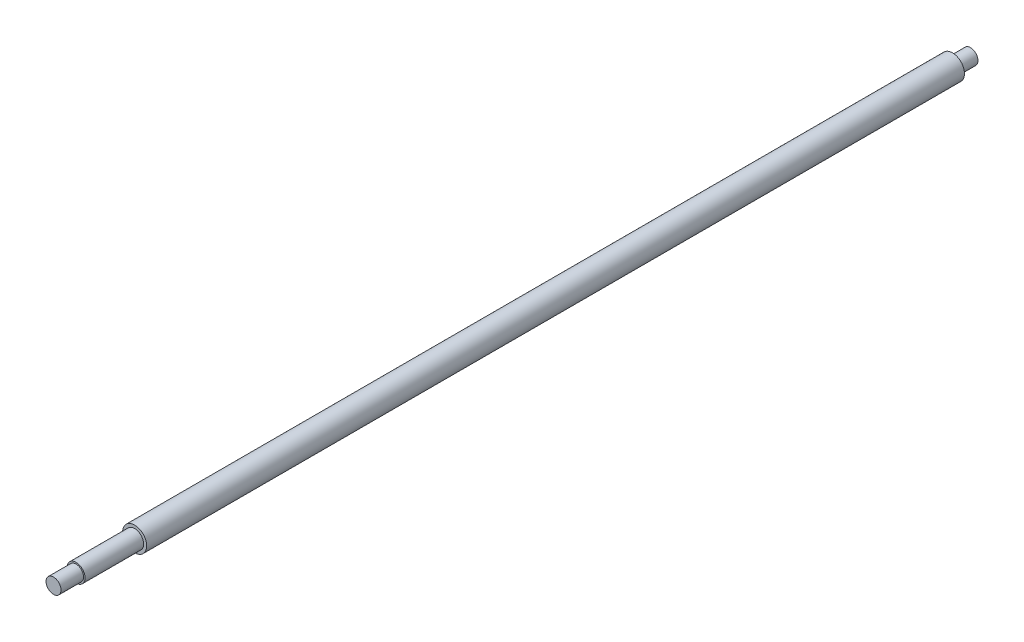
from build123d import *


with BuildPart() as part:
    # Sketch1 → Revolve1 (revolve)
    with BuildSketch(Plane(origin=(0, 0, 0), x_dir=(0, 0, -1), z_dir=(1, 0, 0))):
        Polygon((-610.5, 0), (-610.5, 5), (-595.5, 5), (-595.5, 6), (-556.5, 6), (-556.5, 8), (-12, 8), (-12, 5), (0, 5), (0, 0), align=None)
    revolve(axis=Axis((0, 0, 0), (0, 0, 1)))


solid = part.part
